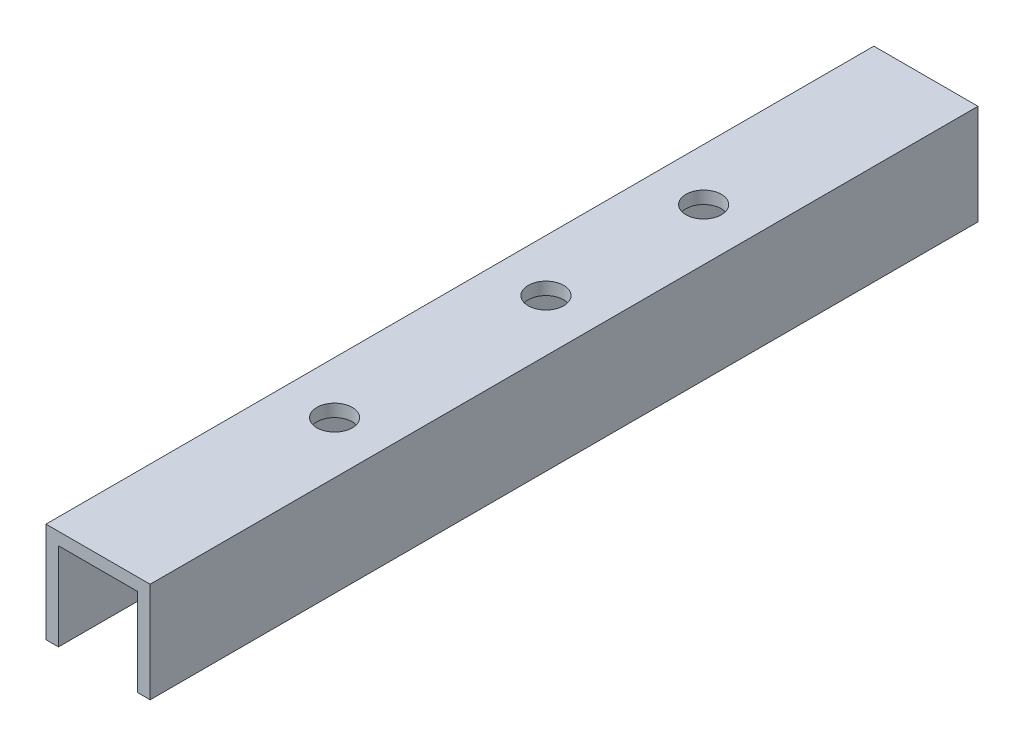
from build123d import *

# Parameters (mm, degrees)
BOSS_EXTRUDE1_DEPTH  = 105
M4_CLEARANCE_HOLE2_D = 4.5


with BuildPart() as part:
    # Sketch1 → Boss-Extrude1 (new body)
    with BuildSketch(Plane.XY):
        Polygon((-6.604, 0), (6.604, 0), (6.604, -12.7), (5.0165, -12.7), (5.0165, -1.5875), (-5.0165, -1.5875), (-5.0165, -12.7), (-6.604, -12.7), align=None)
    extrude(amount=-BOSS_EXTRUDE1_DEPTH)

    # M4 Clearance Hole2 (through all)
    with Locations(Plane(origin=(0, 0, 0), x_dir=(1, 0, 0), z_dir=(0, 1, 0))):
        with Locations((0, 56.807786), (0, 30), (0, 76.807786)):
            Hole(M4_CLEARANCE_HOLE2_D / 2)


solid = part.part
